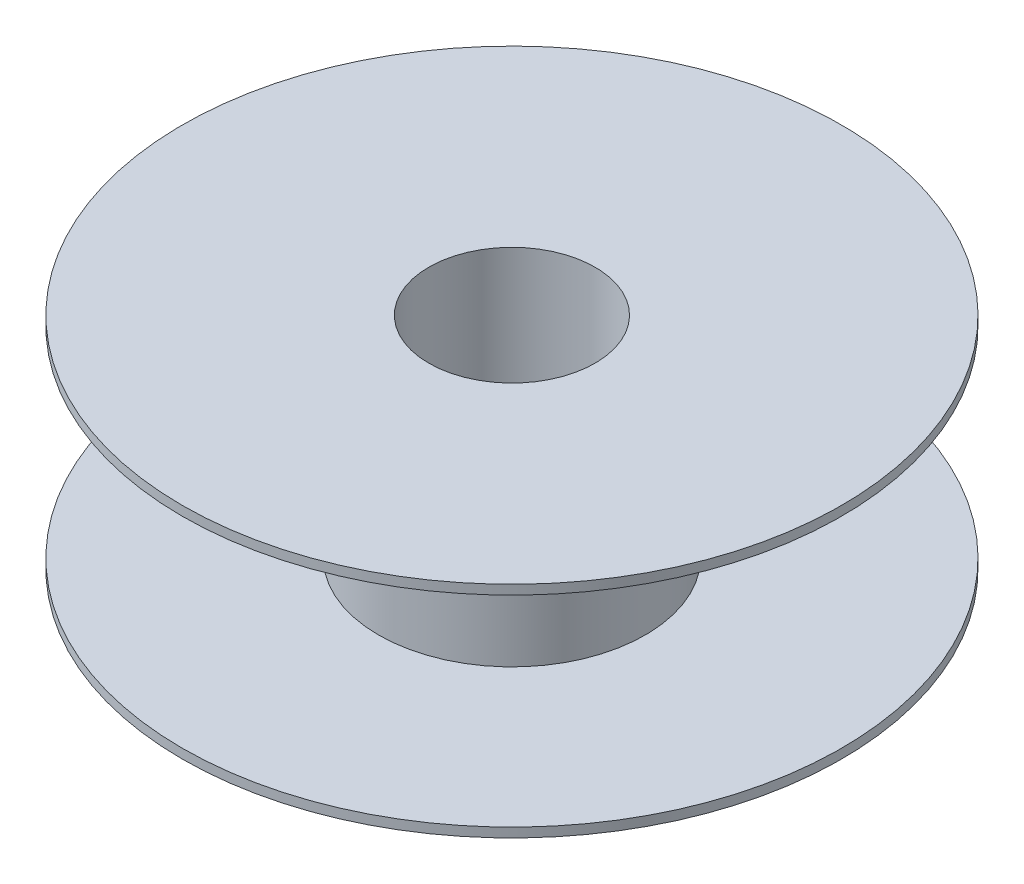
from build123d import *


with BuildPart() as part:
    # Esboço1 → Revolução1 (revolve)
    with BuildSketch(Plane.XY):
        Polygon((26.5, 35), (26.5, -35), (105, -35), (105, -32), (42.5, -32), (42.5, 32), (105, 32), (105, 35), align=None)
    revolve(axis=Axis((0, 23.292230205, 0), (0, -1, 0)))


solid = part.part
